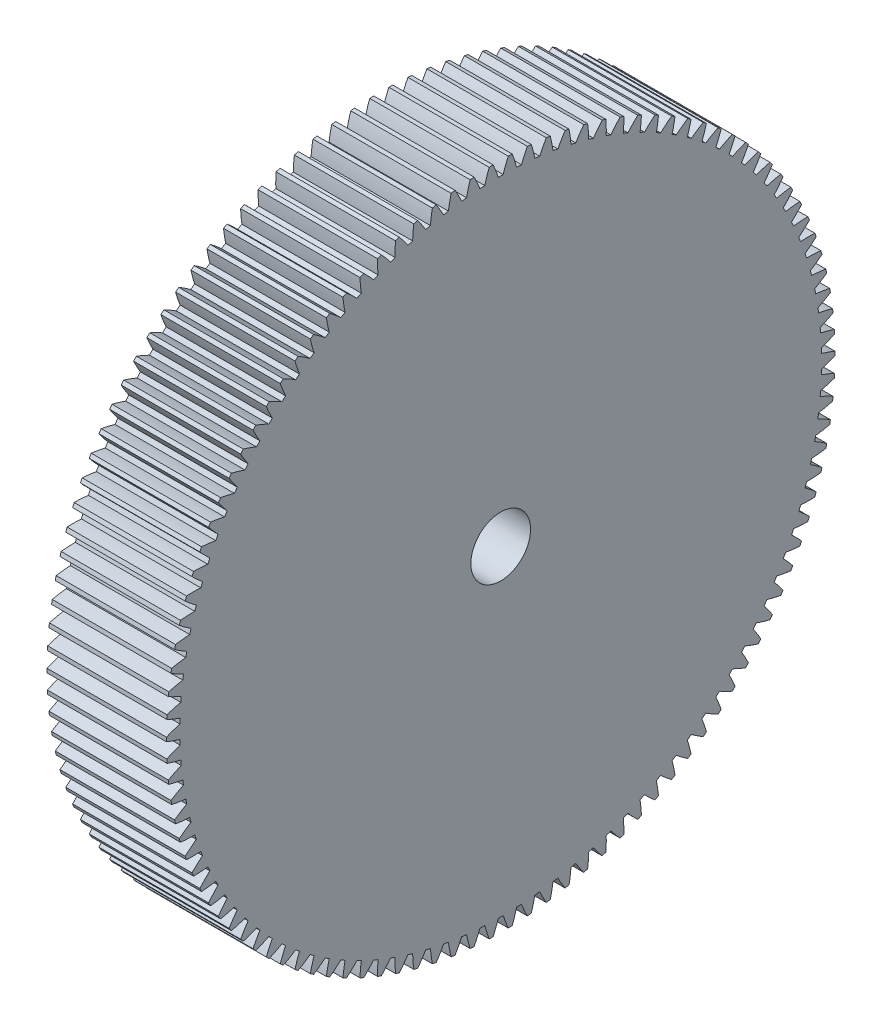
from build123d import *

# Parameters (mm, degrees)
BASPROSKE_W     = 10
BASPROSKE_H     = 28
TOOTHCUT_DEPTH  = 41.841155713
TEETHCUTS_COUNT = 110
TEETHCUTS_ANGLE = 356.727272727
BORSKE_R        = 2.5
BORE_DEPTH      = 50.0000508


with BuildPart() as part:
    # BasProSke → Base-Revolve (revolve)
    with BuildSketch(Plane(origin=(0, 0, 0), x_dir=(1, 0, 0), z_dir=(0, 1, 0)), mode=Mode.PRIVATE) as base_revolve_sk:
        with Locations((5, 14)):
            Rectangle(BASPROSKE_W, BASPROSKE_H)
    revolve(base_revolve_sk.sketch.rotate(Axis((-10, 0, 0), (1, 0, 0)), 180), axis=Axis((-10, 0, 0), (1, 0, 0)))

    # TooCutSke → ToothCut (cut, through all)
    with BuildSketch(Plane(origin=(0, 0, 0), x_dir=(0, 0, -1), z_dir=(1, 0, 0))):
        with BuildLine():
            ThreePointArc((0.206101712, 26.873209672), (0, 26.874), (-0.206101712, 26.873209672))
            ThreePointArc((-0.206101712, 26.873209672), (-0.408646137, 27.451704866), (-0.6430978, 28.018020458))
            ThreePointArc((-0.6430978, 28.018020458), (0, 28.0254), (0.6430978, 28.018020458))
            ThreePointArc((0.6430978, 28.018020458), (0.408646137, 27.451704866), (0.206101712, 26.873209672))
        make_face()
    toothcut = extrude(amount=TOOTHCUT_DEPTH, mode=Mode.SUBTRACT)

    # TeethCuts: ToothCut ×110 about axis
    teethcuts_axis = Axis((-10, 0, 0), (1, 0, 0))
    for i in range(1, TEETHCUTS_COUNT):
        add(toothcut.rotate(teethcuts_axis, i * TEETHCUTS_ANGLE / (TEETHCUTS_COUNT - 1)), mode=Mode.SUBTRACT)

    # BorSke → Bore (cut, symmetric)
    with BuildSketch(Plane(origin=(0, 0, 0), x_dir=(0, 0, -1), z_dir=(1, 0, 0))):
        with Locations(Location((0, 0, 0), (0, 0, 180))):
            Circle(BORSKE_R)
    extrude(amount=BORE_DEPTH, both=True, mode=Mode.SUBTRACT)


solid = part.part
